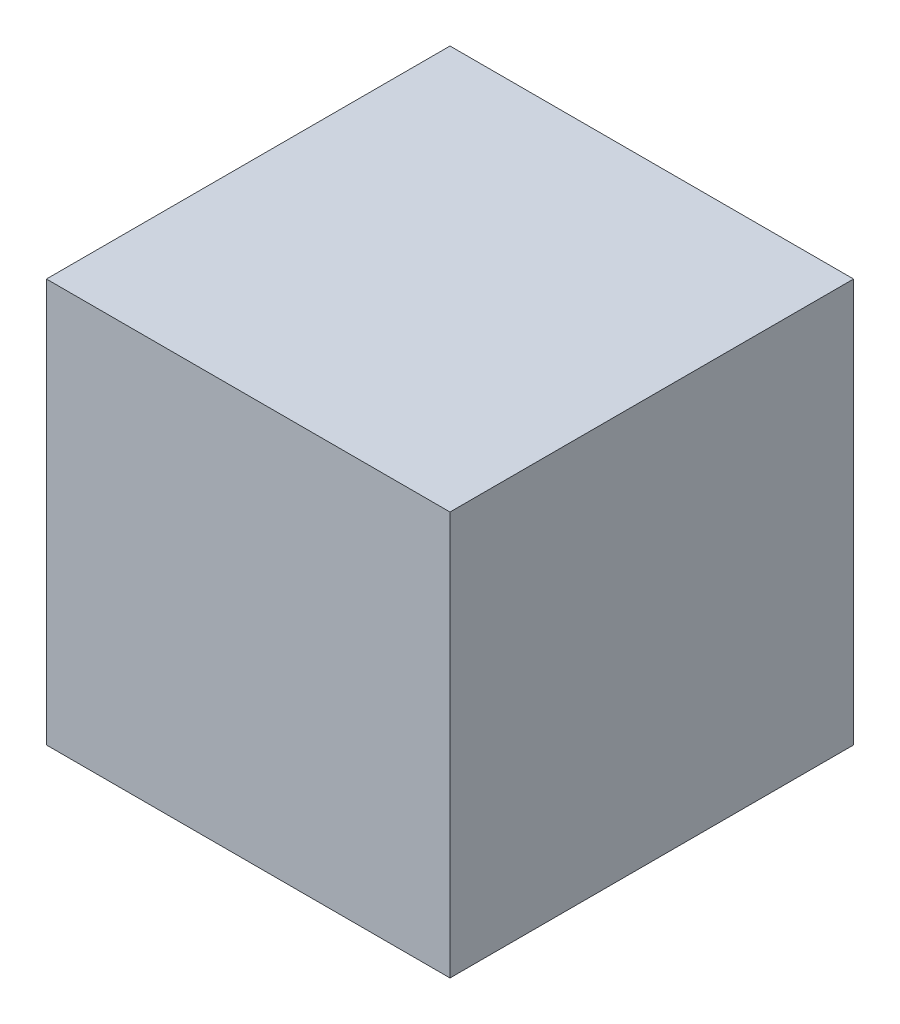
from build123d import *

# Parameters (mm, degrees)
SKETCH1_W           = 200
SKETCH1_H           = 200
BOSS_EXTRUDE1_DEPTH = 200


with BuildPart() as part:
    # Sketch1 → Boss-Extrude1 (new body)
    with BuildSketch(Plane.XY):
        with Locations((90, -90)):
            Rectangle(SKETCH1_W, SKETCH1_H)
    extrude(amount=BOSS_EXTRUDE1_DEPTH)


solid = part.part
